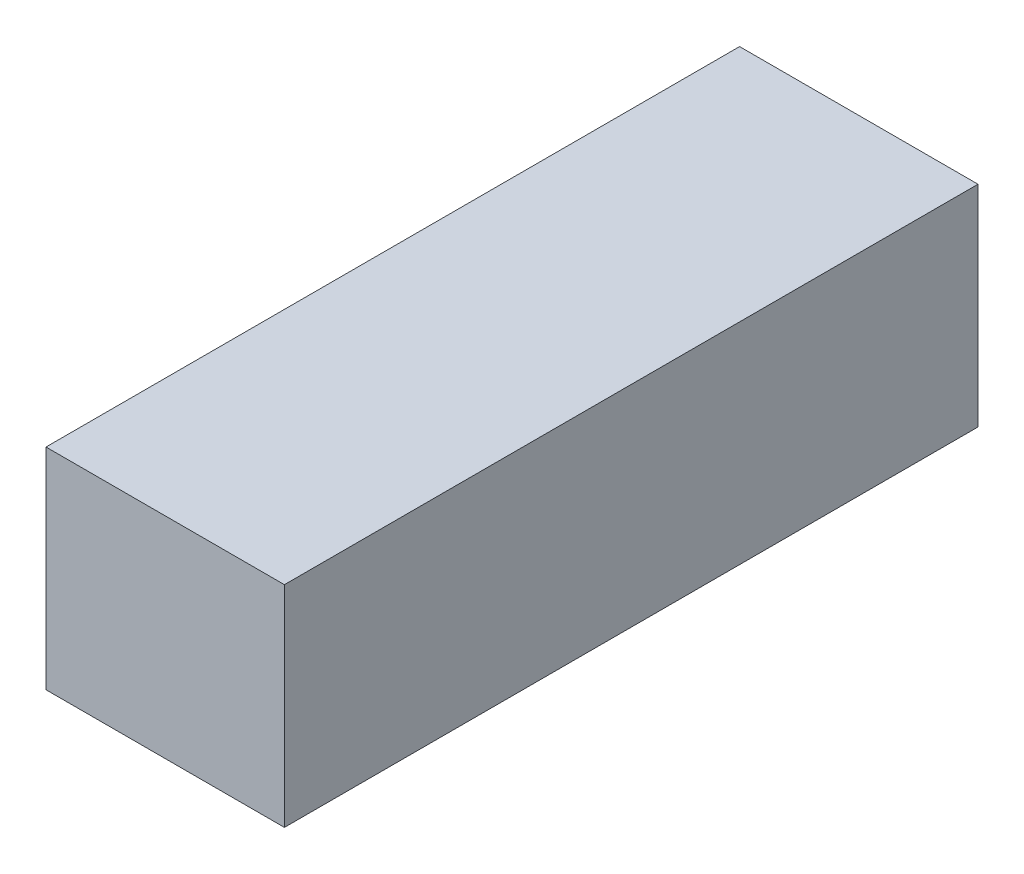
from build123d import *

# Parameters (mm, degrees)
SKETCH_1_W      = 48.5
SKETCH_1_H      = 55
EXTRUDE_1_DEPTH = 160


with BuildPart() as part:
    # ｽｹｯﾁ1 → ﾎﾞｽ - 押し出し1 (new body)
    with BuildSketch(Plane(origin=(0, 0, 0), x_dir=(0, 1, 0), z_dir=(0, 0, 1))):
        with Locations((24.25, 27.5)):
            Rectangle(SKETCH_1_W, SKETCH_1_H)
    extrude(amount=EXTRUDE_1_DEPTH)


solid = part.part
